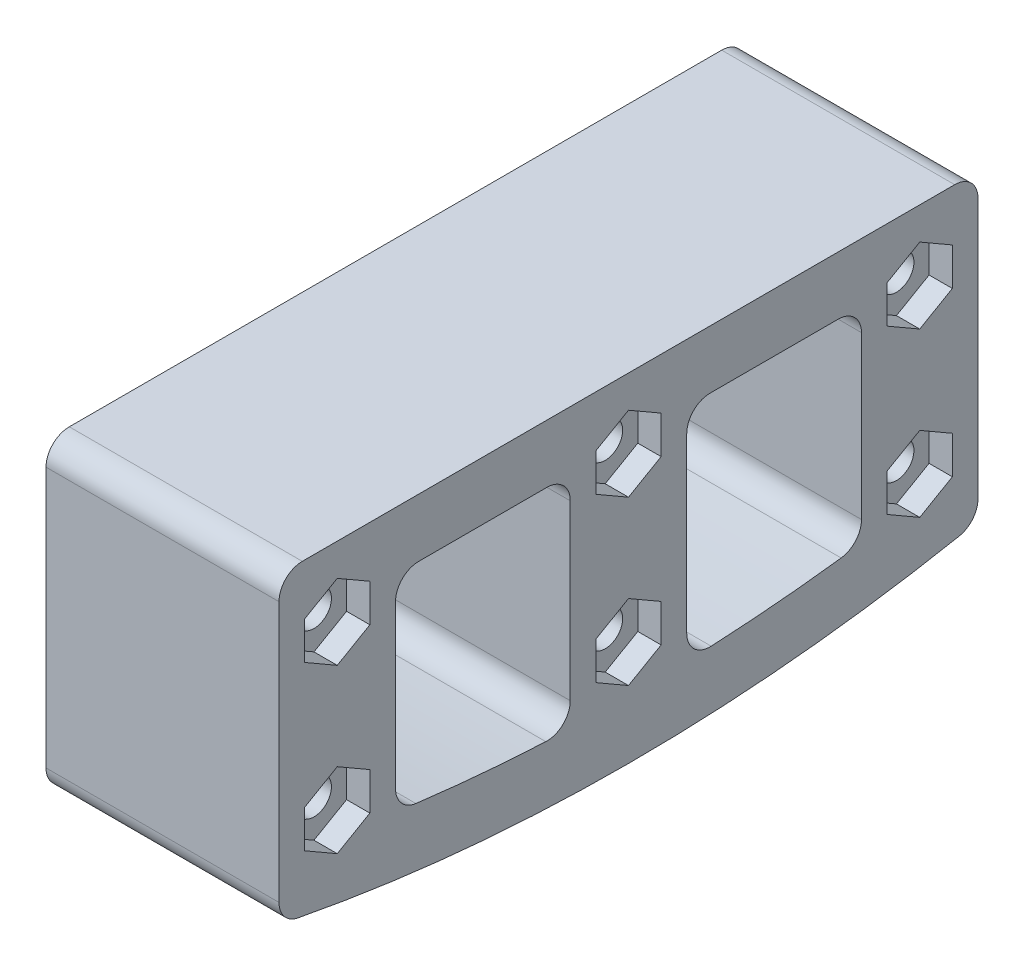
from build123d import *

# Parameters (mm, degrees)
SKETCH1_R           = 1.5
BOSS_EXTRUDE1_DEPTH = 20
CUT_EXTRUDE1_DEPTH  = 2
CUT_EXTRUDE2_START  = 20
CUT_EXTRUDE2_DEPTH  = 2


with BuildPart() as part:
    # Sketch1 → Boss-Extrude1 (new body)
    with BuildSketch(Plane(origin=(0, 0, 0), x_dir=(0, 0, -1), z_dir=(1, 0, 0))):
        with BuildLine():
            Line((-28, 13.216168298), (28, 13.216168298))
            ThreePointArc((28, 13.216168298), (29.414213562, 12.63038186), (30, 11.216168298))
            Line((30, 11.216168298), (30, -11.141664132))
            ThreePointArc((30, -11.141664132), (29.542199202, -12.415093212), (28.378378378, -13.105545442))
            ThreePointArc((28.378378378, -13.105545442), (0, -15.814447135), (-28.378378378, -13.105545442))
            ThreePointArc((-28.378378378, -13.105545442), (-29.542199202, -12.415093212), (-30, -11.141664132))
            Line((-30, -11.141664132), (-30, 11.216168298))
            ThreePointArc((-30, 11.216168298), (-29.414213562, 12.63038186), (-28, 13.216168298))
        make_face()
        with Locations((0, 7.216168298)):
            Circle(SKETCH1_R, mode=Mode.SUBTRACT)
        with Locations((0, -6.783831702)):
            Circle(SKETCH1_R, mode=Mode.SUBTRACT)
        with Locations((-25, 7.216168298)):
            Circle(SKETCH1_R, mode=Mode.SUBTRACT)
        with Locations((-25, -6.783831702)):
            Circle(SKETCH1_R, mode=Mode.SUBTRACT)
        with Locations((25, 7.216168298)):
            Circle(SKETCH1_R, mode=Mode.SUBTRACT)
        with Locations((25, -6.783831702)):
            Circle(SKETCH1_R, mode=Mode.SUBTRACT)
        with BuildLine():
            Line((-20, 6.216168298), (-20, -7.677056726))
            ThreePointArc((-20, -7.677056726), (-19.500582637, -8.999271439), (-18.251748252, -9.661149168))
            ThreePointArc((-18.251748252, -9.661149168), (-12.684282914, -10.258585012), (-7.097902098, -10.640618063))
            ThreePointArc((-7.097902098, -10.640618063), (-5.620834346, -10.091429355), (-5, -8.643015706))
            Line((-5, -8.643015706), (-5, 6.216168298))
            ThreePointArc((-5, 6.216168298), (-5.585786438, 7.63038186), (-7, 8.216168298))
            Line((-7, 8.216168298), (-18, 8.216168298))
            ThreePointArc((-18, 8.216168298), (-19.414213562, 7.63038186), (-20, 6.216168298))
        make_face(mode=Mode.SUBTRACT)
        with BuildLine():
            Line((5, 6.216168298), (5, -8.643015706))
            ThreePointArc((5, -8.643015706), (5.620834346, -10.091429355), (7.097902098, -10.640618063))
            ThreePointArc((7.097902098, -10.640618063), (12.684282914, -10.258585012), (18.251748252, -9.661149168))
            ThreePointArc((18.251748252, -9.661149168), (19.500582637, -8.999271439), (20, -7.677056726))
            Line((20, -7.677056726), (20, 6.216168298))
            ThreePointArc((20, 6.216168298), (19.414213562, 7.63038186), (18, 8.216168298))
            Line((18, 8.216168298), (7, 8.216168298))
            ThreePointArc((7, 8.216168298), (5.585786438, 7.63038186), (5, 6.216168298))
        make_face(mode=Mode.SUBTRACT)
    extrude(amount=BOSS_EXTRUDE1_DEPTH)

    # Sketch2 → Cut-Extrude1 (cut)
    with BuildSketch(Plane(origin=(0, 0, 0), x_dir=(0, 0, -1), z_dir=(1, 0, 0))):
        Polygon((-25, 3.983006791), (-22.2, 5.599587544), (-22.2, 8.832749052), (-25, 10.449329806), (-27.8, 8.832749052), (-27.8, 5.599587544), align=None)
        Polygon((-25, -10.016993209), (-22.2, -8.400412456), (-22.2, -5.167250948), (-25, -3.550670194), (-27.8, -5.167250948), (-27.8, -8.400412456), align=None)
        Polygon((0, 3.983006791), (2.8, 5.599587544), (2.8, 8.832749052), (0, 10.449329806), (-2.8, 8.832749052), (-2.8, 5.599587544), align=None)
        Polygon((0, -10.016993209), (2.8, -8.400412456), (2.8, -5.167250948), (0, -3.550670194), (-2.8, -5.167250948), (-2.8, -8.400412456), align=None)
        Polygon((25, 3.983006791), (27.8, 5.599587544), (27.8, 8.832749052), (25, 10.449329806), (22.2, 8.832749052), (22.2, 5.599587544), align=None)
        Polygon((25, -10.016993209), (27.8, -8.400412456), (27.8, -5.167250948), (25, -3.550670194), (22.2, -5.167250948), (22.2, -8.400412456), align=None)
    extrude(amount=CUT_EXTRUDE1_DEPTH, mode=Mode.SUBTRACT)

    # Sketch2_2 → Cut-Extrude2 (cut)
    with BuildSketch(Plane(origin=(0, 0, 0), x_dir=(0, 0, -1), z_dir=(1, 0, 0)).offset(CUT_EXTRUDE2_START)):
        Polygon((-25, 3.983006791), (-22.2, 5.599587544), (-22.2, 8.832749052), (-25, 10.449329806), (-27.8, 8.832749052), (-27.8, 5.599587544), align=None)
        Polygon((-25, -10.016993209), (-22.2, -8.400412456), (-22.2, -5.167250948), (-25, -3.550670194), (-27.8, -5.167250948), (-27.8, -8.400412456), align=None)
        Polygon((0, 3.983006791), (2.8, 5.599587544), (2.8, 8.832749052), (0, 10.449329806), (-2.8, 8.832749052), (-2.8, 5.599587544), align=None)
        Polygon((0, -10.016993209), (2.8, -8.400412456), (2.8, -5.167250948), (0, -3.550670194), (-2.8, -5.167250948), (-2.8, -8.400412456), align=None)
        Polygon((25, 3.983006791), (27.8, 5.599587544), (27.8, 8.832749052), (25, 10.449329806), (22.2, 8.832749052), (22.2, 5.599587544), align=None)
        Polygon((25, -10.016993209), (27.8, -8.400412456), (27.8, -5.167250948), (25, -3.550670194), (22.2, -5.167250948), (22.2, -8.400412456), align=None)
    extrude(amount=-CUT_EXTRUDE2_DEPTH, mode=Mode.SUBTRACT)


solid = part.part
